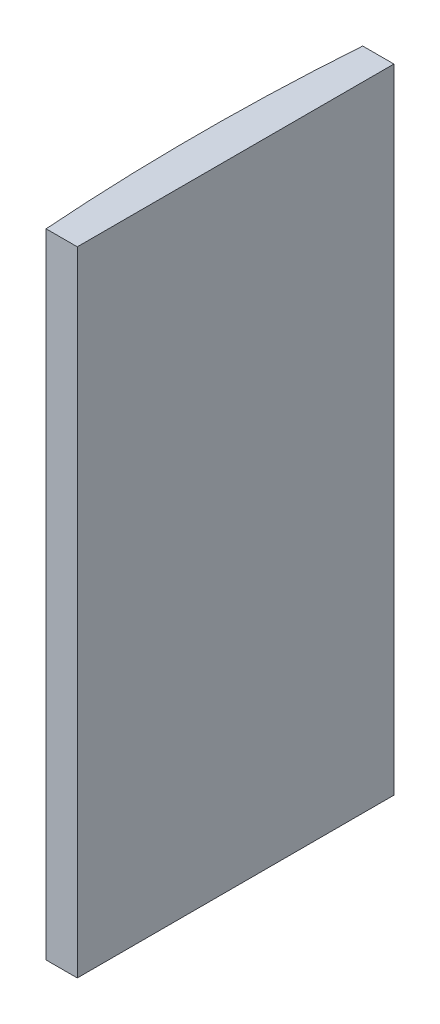
from build123d import *

# Parameters (mm, degrees)
EXTRUDE_1_DEPTH = 60


with BuildPart() as part:
    # 草图1 → 凸台-拉伸1 (new body)
    with BuildSketch(Plane(origin=(0, 0, 0), x_dir=(1, 0, 0), z_dir=(0, 1, 0))):
        with BuildLine():
            Line((-201.900074385, 15), (-198.944795665, 15))
            Line((-198.944795665, 15), (-198.944795665, -15))
            Line((-198.944795665, -15), (-201.900074385, -15))
            ThreePointArc((-201.900074385, -15), (-202.444795665, 0), (-201.900074385, 15))
        make_face()
    extrude(amount=EXTRUDE_1_DEPTH)


solid = part.part
